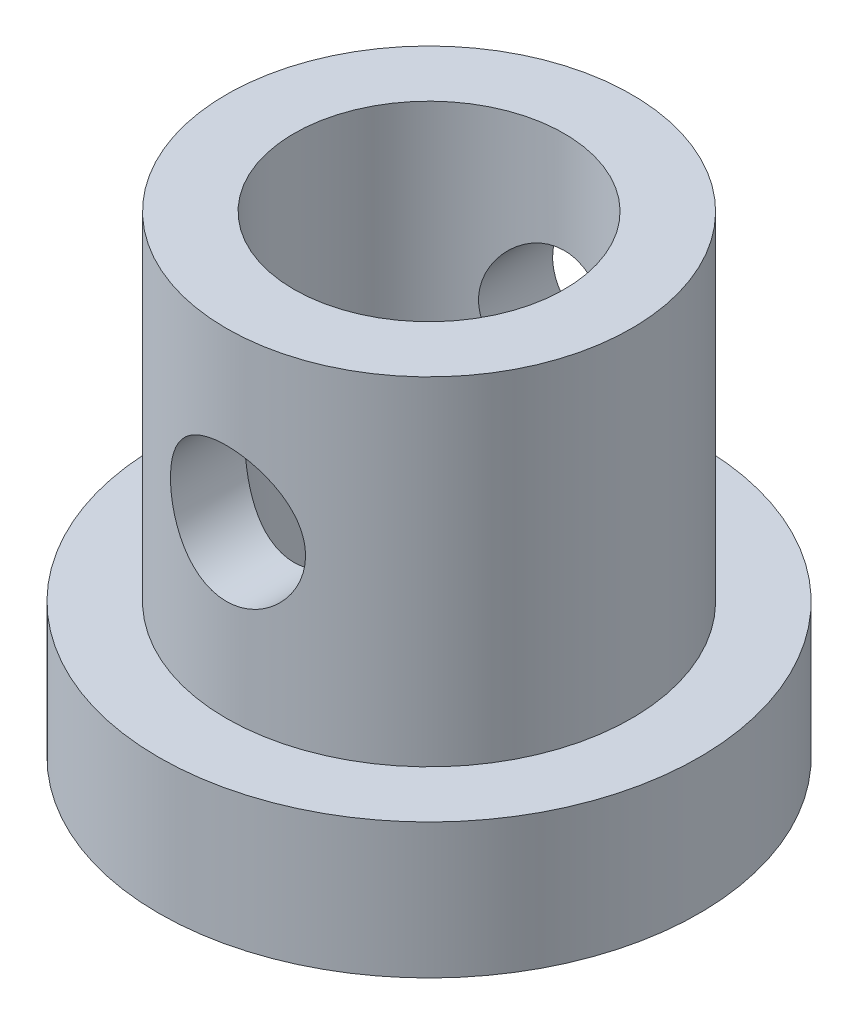
from build123d import *

# Parameters (mm, degrees)
SKETCH2_R               = 4
SKETCH2_R_2             = 2
BOSS_EXTRUDE1_DEPTH     = 2
SKETCH3_R               = 3
SKETCH3_R_2             = 2
BOSS_EXTRUDE2_DEPTH     = 5
SKETCH4_R               = 1
CUT_EXTRUDE1_DEPTH      = 5
CUT_EXTRUDE1_DEPTH_BACK = 5


with BuildPart() as part:
    # Sketch2 → Boss-Extrude1 (new body)
    with BuildSketch(Plane(origin=(0, 0, 0), x_dir=(1, 0, 0), z_dir=(0, 1, 0))):
        Circle(SKETCH2_R)
        Circle(SKETCH2_R_2, mode=Mode.SUBTRACT)
    extrude(amount=BOSS_EXTRUDE1_DEPTH)

    # Sketch3 → Boss-Extrude2 (add)
    with BuildSketch(Plane(origin=(0, 2, 0), x_dir=(1, 0, 0), z_dir=(0, 1, 0))):
        Circle(SKETCH3_R)
        Circle(SKETCH3_R_2, mode=Mode.SUBTRACT)
    extrude(amount=BOSS_EXTRUDE2_DEPTH)

    # Sketch4 → Cut-Extrude1 (cut, two sides)
    with BuildSketch(Plane.XY) as cut_extrude1_sk:
        with Locations((0, 4.5)):
            Circle(SKETCH4_R)
    extrude(amount=CUT_EXTRUDE1_DEPTH, mode=Mode.SUBTRACT)
    extrude(cut_extrude1_sk.sketch, amount=-CUT_EXTRUDE1_DEPTH_BACK, mode=Mode.SUBTRACT)


solid = part.part
